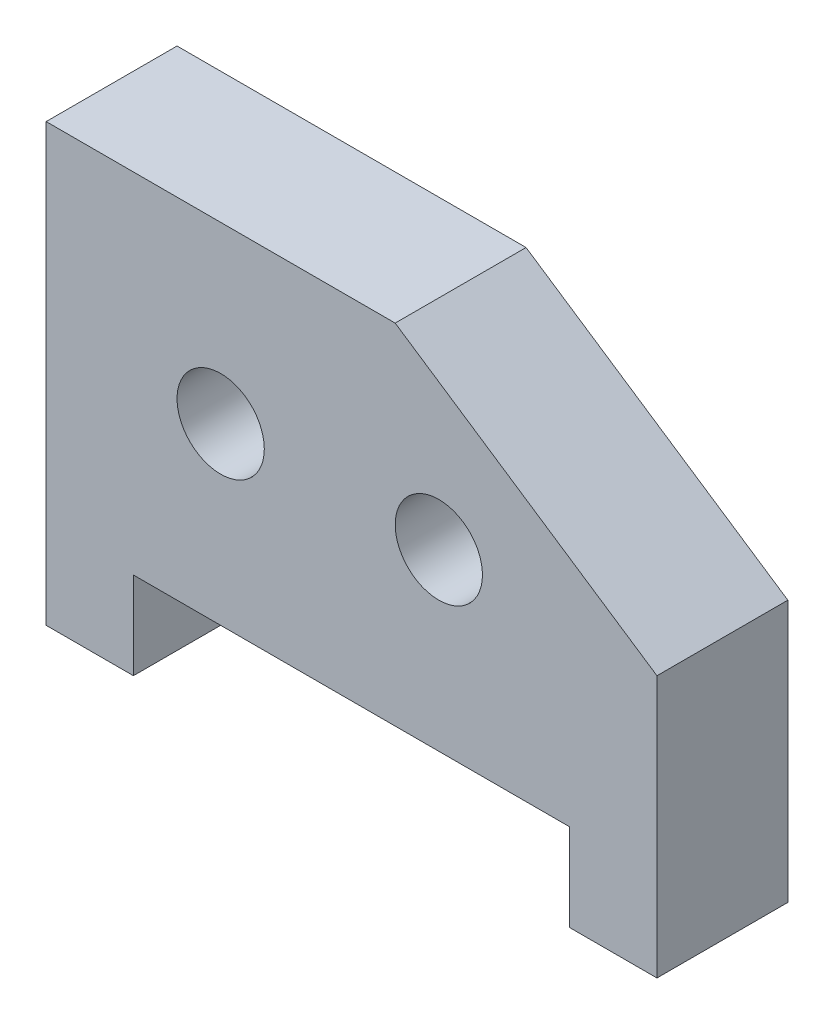
from build123d import *

# Parameters (mm, degrees)
SKETCH1_R           = 6.35
BOSS_EXTRUDE1_DEPTH = 19.05


with BuildPart() as part:
    # Sketch1 → Boss-Extrude1 (new body)
    with BuildSketch(Plane.XY):
        Polygon((-1.304733728, 61.99852071), (-1.304733728, -1.50147929), (11.395266272, -1.50147929), (11.395266272, 11.19852071), (74.895266272, 11.19852071), (74.895266272, -1.50147929), (87.595266272, -1.50147929), (87.595266272, 36.59852071), (49.495266272, 61.99852071), align=None)
        with Locations((24.095266272, 36.59852071)):
            Circle(SKETCH1_R, mode=Mode.SUBTRACT)
        with Locations((55.845266272, 36.59852071)):
            Circle(SKETCH1_R, mode=Mode.SUBTRACT)
    extrude(amount=BOSS_EXTRUDE1_DEPTH)


solid = part.part
